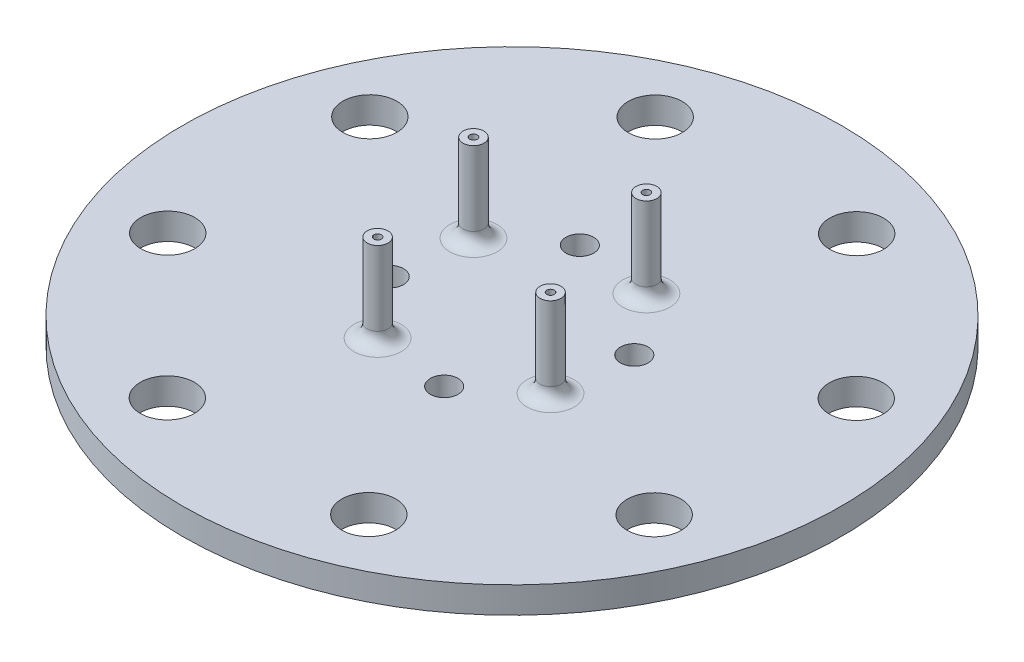
from build123d import *

# Parameters (mm, degrees)
SKETCH1_R           = 25
BOSS_EXTRUDE1_DEPTH = 2
SKETCH2_R           = 1.05
SKETCH2_R_2         = 0.79375
CUT_EXTRUDE1_DEPTH  = 3
SKETCH4_R           = 2.05
CUT_EXTRUDE3_DEPTH  = 3
SKETCH7_R           = 0.79375
SKETCH7_R_2         = 0.28575
BOSS_EXTRUDE2_DEPTH = 8.64
FILLET1_R           = 1
FILLET2_R           = 1
FILLET3_R           = 1
FILLET4_R           = 1


with BuildPart() as part:
    # Sketch1 → Boss-Extrude1 (new body)
    with BuildSketch(Plane(origin=(0, 0, 0), x_dir=(1, 0, 0), z_dir=(0, 1, 0))):
        Circle(SKETCH1_R)
    extrude(amount=BOSS_EXTRUDE1_DEPTH)

    # Sketch2 → Cut-Extrude1 (cut, through all)
    with BuildSketch(Plane(origin=(0, 2, 0), x_dir=(1, 0, 0), z_dir=(0, 1, 0))):
        with Locations((-2.066368974, 7.209723938)):
            Circle(SKETCH2_R)
        with Locations((7.209723938, 2.066368974)):
            Circle(SKETCH2_R)
        with Locations((2.066368974, -7.209723938)):
            Circle(SKETCH2_R)
        with Locations((-7.209723938, -2.066368974)):
            Circle(SKETCH2_R)
        with Locations((-3.636901173, -6.559188201)):
            Circle(SKETCH2_R_2)
        with Locations((-6.559188201, 3.636901173)):
            Circle(SKETCH2_R_2)
        with Locations((3.636901173, 6.559188201)):
            Circle(SKETCH2_R_2)
        with Locations((6.559188201, -3.636901173)):
            Circle(SKETCH2_R_2)
    extrude(amount=-CUT_EXTRUDE1_DEPTH, mode=Mode.SUBTRACT)

    # Sketch4 → Cut-Extrude3 (cut, through all)
    with BuildSketch(Plane.XZ):
        with Locations((-18.488747294, 7.626678405)):
            Circle(SKETCH4_R)
        with Locations((-7.680642569, 18.466394605)):
            Circle(SKETCH4_R)
        with Locations((7.626678405, 18.488747294)):
            Circle(SKETCH4_R)
        with Locations((18.466394605, 7.680642569)):
            Circle(SKETCH4_R)
        with Locations((18.488747294, -7.626678405)):
            Circle(SKETCH4_R)
        with Locations((7.680642569, -18.466394605)):
            Circle(SKETCH4_R)
        with Locations((-7.626678405, -18.488747294)):
            Circle(SKETCH4_R)
        with Locations((-18.466394605, -7.680642569)):
            Circle(SKETCH4_R)
    extrude(amount=-CUT_EXTRUDE3_DEPTH, mode=Mode.SUBTRACT)

    # Sketch7 → Boss-Extrude2 (add)
    with BuildSketch(Plane(origin=(0, 0, 0), x_dir=(1, 0, 0), z_dir=(0, 1, 0))):
        with Locations((-3.636901173, -6.559188201)):
            Circle(SKETCH7_R)
        with Locations((-3.636901173, -6.559188201)):
            Circle(SKETCH7_R_2, mode=Mode.SUBTRACT)
        with Locations((6.559188201, -3.636901173)):
            Circle(SKETCH7_R)
        with Locations((6.559188201, -3.636901173)):
            Circle(SKETCH7_R_2, mode=Mode.SUBTRACT)
        with Locations((-6.559188201, 3.636901173)):
            Circle(SKETCH7_R)
        with Locations((-6.559188201, 3.636901173)):
            Circle(SKETCH7_R_2, mode=Mode.SUBTRACT)
        with Locations((3.636901173, 6.559188201)):
            Circle(SKETCH7_R)
        with Locations((3.636901173, 6.559188201)):
            Circle(SKETCH7_R_2, mode=Mode.SUBTRACT)
    extrude(amount=BOSS_EXTRUDE2_DEPTH)

    # Fillet1
    fillet1_edges = [part.edges().sort_by_distance(p)[0] for p in [
        (-7.352938201, 2, -3.636901173),
    ]]
    fillet(fillet1_edges, radius=FILLET1_R)

    # Fillet2
    fillet2_edges = [part.edges().sort_by_distance(p)[0] for p in [
        (-4.430651173, 2, 6.559188201),
    ]]
    fillet(fillet2_edges, radius=FILLET2_R)

    # Fillet3
    fillet3_edges = [part.edges().sort_by_distance(p)[0] for p in [
        (5.765438201, 2, 3.636901173),
    ]]
    fillet(fillet3_edges, radius=FILLET3_R)

    # Fillet4
    fillet4_edges = [part.edges().sort_by_distance(p)[0] for p in [
        (2.843151173, 2, -6.559188201),
    ]]
    fillet(fillet4_edges, radius=FILLET4_R)


solid = part.part
